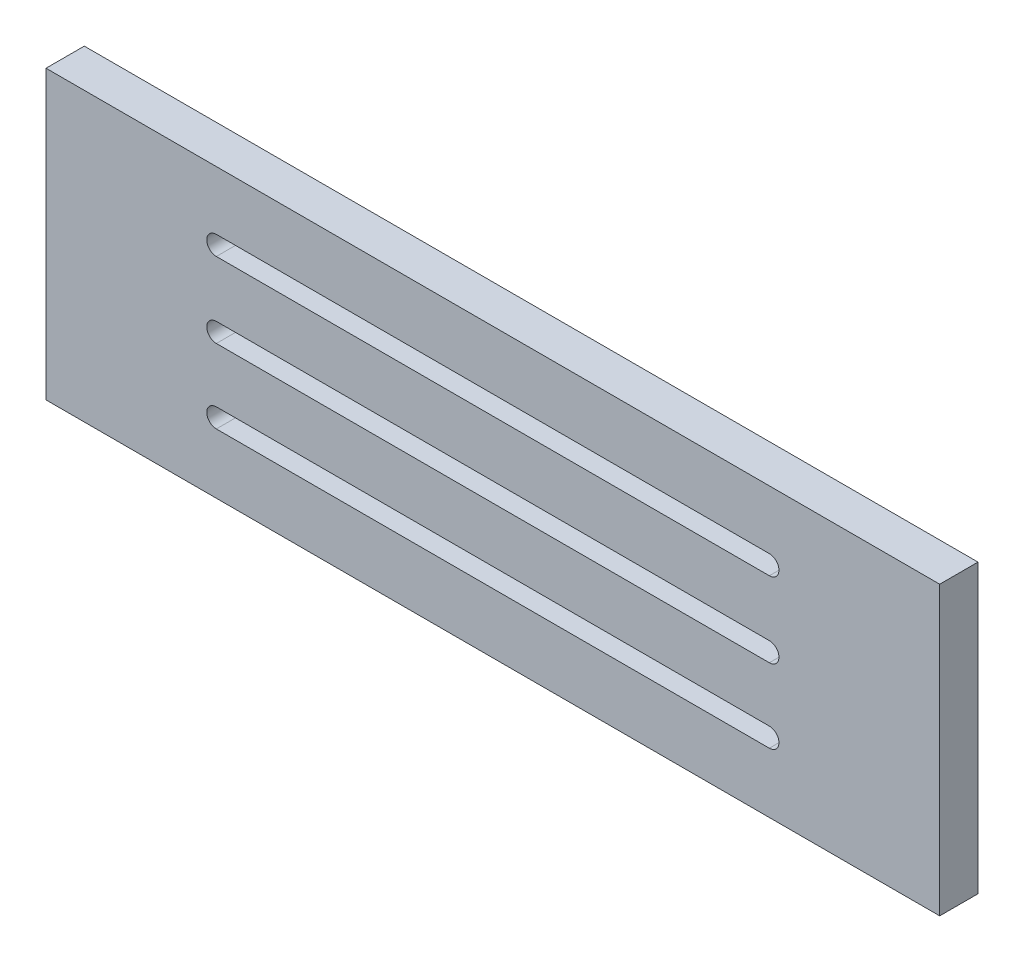
from build123d import *

# Parameters (mm, degrees)
SKETCH1_W           = 140
SKETCH1_H           = 45
BOSS_EXTRUDE1_DEPTH = 6


with BuildPart() as part:
    # Sketch1 → Boss-Extrude1 (new body)
    with BuildSketch(Plane.XY):
        with Locations((70, 22.5)):
            Rectangle(SKETCH1_W, SKETCH1_H)
        with BuildLine():
            Line((26.683203231, 24), (113.316796769, 24))
            ThreePointArc((113.316796769, 24), (114.816796769, 22.5), (113.316796769, 21))
            Line((113.316796769, 21), (26.683203231, 21))
            ThreePointArc((26.683203231, 21), (25.183203231, 22.5), (26.683203231, 24))
        make_face(mode=Mode.SUBTRACT)
        with BuildLine():
            Line((26.683203231, 35.803698148), (113.316796769, 35.803698148))
            ThreePointArc((113.316796769, 35.803698148), (114.816796769, 34.303698148), (113.316796769, 32.803698148))
            Line((113.316796769, 32.803698148), (26.683203231, 32.803698148))
            ThreePointArc((26.683203231, 32.803698148), (25.183203231, 34.303698148), (26.683203231, 35.803698148))
        make_face(mode=Mode.SUBTRACT)
        with BuildLine():
            Line((26.683203231, 12.405318703), (113.316796769, 12.405318703))
            ThreePointArc((113.316796769, 12.405318703), (114.816796769, 10.905318703), (113.316796769, 9.405318703))
            Line((113.316796769, 9.405318703), (26.683203231, 9.405318703))
            ThreePointArc((26.683203231, 9.405318703), (25.183203231, 10.905318703), (26.683203231, 12.405318703))
        make_face(mode=Mode.SUBTRACT)
    extrude(amount=BOSS_EXTRUDE1_DEPTH)


solid = part.part
